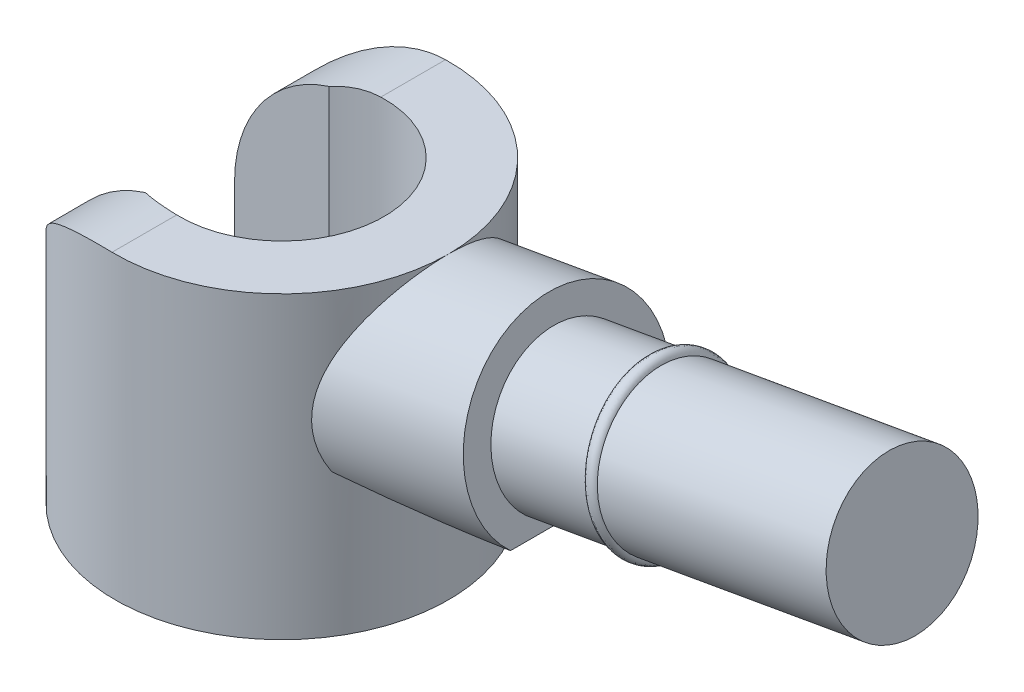
from build123d import *

# Parameters (mm, degrees)
SKETCH1_R                            = 2.45
BOSS_EXTRUDE1_DEPTH                  = 4.4
SKETCH2_R                            = 1.5
CUT_EXTRUDE4_DEPTH                   = 6.600446411
SKETCH4_W                            = 4.500126036
SKETCH4_H                            = 2.7
CUT_EXTRUDE6_DEPTH                   = 6.600446411
CUT_EXTRUDE7_DEPTH                   = 7.308922253
CUT_EXTRUDE7_DEPTH_BACK              = 7.308922253
SKETCH15_R                           = 1.5
BOSS_EXTRUDE2_DEPTH                  = 1.5
BOSS_EXTRUDE2_DIRECTION_2_REACH      = 8.897
BOSS_EXTRUDE2_DIRECTION_2_END_RADIUS = 2.45
SKETCH17_R                           = 1.1
BOSS_EXTRUDE3_DEPTH                  = 5
CUT_EXTRUDE8_REACH                   = 10.672
CUT_EXTRUDE8_END_RADIUS              = 2.45
SKETCH22_W                           = 3.41388459
SKETCH22_H                           = 0.789073042
SKETCH23_R                           = 0.1


with BuildPart() as part:
    # Sketch1 → Boss-Extrude1 (new body)
    with BuildSketch(Plane(origin=(0, 0, 0), x_dir=(1, 0, 0), z_dir=(0, 1, 0))):
        with Locations(Location((0, 0, 0), (0, 0, 270))):
            Circle(SKETCH1_R)
    extrude(amount=BOSS_EXTRUDE1_DEPTH)

    # Sketch2 → Cut-Extrude4 (cut, through all)
    with BuildSketch(Plane(origin=(0, 4.4, 0), x_dir=(1, 0, 0), z_dir=(0, 1, 0))):
        with Locations(Location((0, 0, 0), (0, 0, 270))):
            Circle(SKETCH2_R)
    extrude(amount=-CUT_EXTRUDE4_DEPTH, mode=Mode.SUBTRACT)

    # Sketch4 → Cut-Extrude6 (cut, through all)
    with BuildSketch(Plane(origin=(0, 0, 0), x_dir=(1, 0, 0), z_dir=(0, 1, 0))):
        with Locations((-2.90389786, 0)):
            Rectangle(SKETCH4_W, SKETCH4_H)
    extrude(amount=CUT_EXTRUDE6_DEPTH, mode=Mode.SUBTRACT)

    # Sketch11 → Cut-Extrude7 (cut, two sides)
    with BuildSketch(Plane(origin=(0, 0, 1.35), x_dir=(-1, 0, 0), z_dir=(0, 0, -1))) as cut_extrude7_sk:
        with BuildLine():
            Line((2.04450483, 2.4), (2.911847468, 2.4))
            Line((2.911847468, 2.4), (2.911847468, 5.613196254))
            Line((2.911847468, 5.613196254), (0.04450483, 5.613196254))
            Line((0.04450483, 5.613196254), (0.04450483, 4.4))
            ThreePointArc((0.04450483, 4.4), (1.458718392, 3.814213562), (2.04450483, 2.4))
        make_face()
    extrude(amount=CUT_EXTRUDE7_DEPTH, mode=Mode.SUBTRACT)
    extrude(cut_extrude7_sk.sketch, amount=-CUT_EXTRUDE7_DEPTH_BACK, mode=Mode.SUBTRACT)


with BuildPart() as boss_extrude2_tool:
    # Sketch15 → Boss-Extrude2 (new body)
    with BuildSketch(Plane(origin=(3.128567776, 0.55165091, 0), x_dir=(0, 0, 1), z_dir=(-0.9848077530122092, -0.1736481776669237, 0))):
        with Locations(Location((0, 2.407716078, 0), (0, 0, 90))):
            Circle(SKETCH15_R)
    extrude(amount=-BOSS_EXTRUDE2_DEPTH)


with BuildPart() as part_1:
    add(part.part)


with BuildPart() as part_2:
    # Boss-Extrude2: joined with boss_extrude2_tool
    add(part_1.part.fuse(boss_extrude2_tool.part, tol=0.00001))

    # Boss-Extrude2 direction 2: up to this cylinder (the profile starts outside it)
    boss_extrude2_direction_2_end = Plane(origin=(0, 2.922788, 0), z_dir=(0, -1, 0)) * Cylinder(BOSS_EXTRUDE2_DIRECTION_2_END_RADIUS, 23.694, mode=Mode.PRIVATE)
    # Sketch15 → Boss-Extrude2 direction 2 (add, up to the surface)
    with BuildSketch(Plane(origin=(3.128567776, 0.55165091, 0), x_dir=(0, 0, 1), z_dir=(-0.9848077530122092, -0.1736481776669237, 0)), mode=Mode.PRIVATE) as boss_extrude2_direction_2_sk1:
        with Locations(Location((0, 2.407716078, 0), (0, 0, 90))):
            Circle(SKETCH15_R)
    boss_extrude2_direction_2_tool1 = extrude(boss_extrude2_direction_2_sk1.sketch, amount=BOSS_EXTRUDE2_DIRECTION_2_REACH, mode=Mode.PRIVATE) - boss_extrude2_direction_2_end
    add(boss_extrude2_direction_2_tool1.solids().sort_by_distance((2.710472, 2.922788, 0))[0])

    # Sketch17 → Boss-Extrude3 (add)
    with BuildSketch(Plane(origin=(4.605779405, 0.812123176, 0), x_dir=(0, 0, -1), z_dir=(0.9848077530122092, 0.1736481776669237, 0))):
        with Locations(Location((0, 2.407716078, 0), (0, 0, 270))):
            Circle(SKETCH17_R)
    extrude(amount=BOSS_EXTRUDE3_DEPTH)

    # Cut-Extrude8: up to this cylinder (the profile starts outside it)
    cut_extrude8_end = Plane(origin=(0, 1.705436, 0), z_dir=(0, -1, 0)) * Cylinder(CUT_EXTRUDE8_END_RADIUS, 27.244, mode=Mode.PRIVATE)
    # Sketch22 → Cut-Extrude8 (cut, up to the surface)
    with BuildSketch(Plane(origin=(4.5, 0, 0), x_dir=(0, 0, -1), z_dir=(1, 0, 0)), mode=Mode.PRIVATE) as cut_extrude8_sk1:
        with Locations((0.114225606, 1.705435588)):
            Rectangle(SKETCH22_W, SKETCH22_H)
    cut_extrude8_tool1 = extrude(cut_extrude8_sk1.sketch, amount=-CUT_EXTRUDE8_REACH, mode=Mode.PRIVATE) - cut_extrude8_end
    add(cut_extrude8_tool1.solids().sort_by_distance((4.5, 1.705436, -0.114226))[0], mode=Mode.SUBTRACT)

    # Sweep1: sweep along a path in Sketch20
    with BuildLine(Plane(origin=(6.082991035, 1.072595443, 0), x_dir=(0, 0, 1), z_dir=(-0.9848077530122092, -0.1736481776669237, 0))) as sweep1_path:
        EllipticalCenterArc((0, 2.407716078), 1.15, 1.1, start_angle=0, arc_size=360, rotation=-90)
    # Sketch23 → Sweep1 (sweep)
    with BuildSketch(Plane.XY):
        with Locations((5.47388253, 4.527021432)):
            Circle(SKETCH23_R)
    sweep(path=sweep1_path.line)


solid = part_2.part
